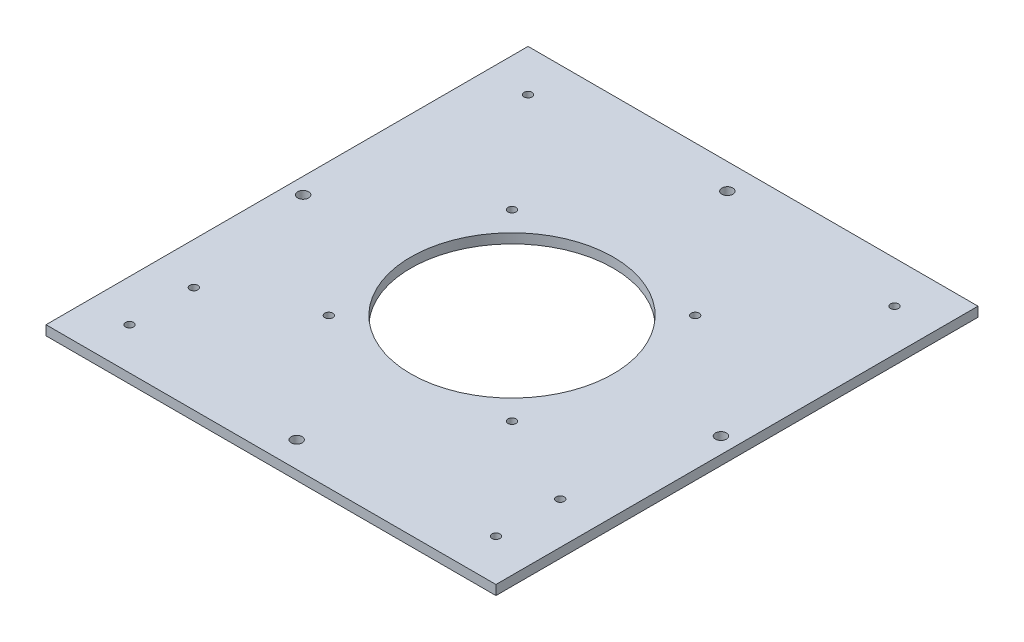
from build123d import *

# Parameters (mm, degrees)
SKETCH_1_W           = 140
SKETCH_1_H           = 3
EXTRUDE_1_DEPTH      = 150
CUT_EXTRUDE_1_REACH  = 5
SKETCH_2_R           = 31.5
HOLE_WIZARD_M3_1_D   = 2.5
HOLE_WIZARD_M3_1_2_D = 3.4
HOLE_WIZARD_M3_2_D   = 2.5


with BuildPart() as part:
    # 草图1 → 拉伸-薄壁1 (new body)
    with BuildSketch(Plane.XY):
        with Locations((82, 225.557982809)):
            Rectangle(SKETCH_1_W, SKETCH_1_H)
    extrude(amount=EXTRUDE_1_DEPTH)

    # 草图2 → 切除-拉伸1 (cut, up to next)
    with BuildSketch(Plane.XZ.offset(-224.057982809), mode=Mode.PRIVATE) as cut_extrude_1_sk1:
        with Locations((82, 75)):
            Circle(SKETCH_2_R)
    cut_extrude_1_tool1 = extrude(cut_extrude_1_sk1.sketch, amount=-CUT_EXTRUDE_1_REACH, mode=Mode.PRIVATE) & part.part
    add(cut_extrude_1_tool1.solids().sort_by_distance((82, 224.057983, 75))[0], mode=Mode.SUBTRACT)

    # Hole Wizard M3 _1 (through all)
    with Locations(Plane(origin=(0, 224.057982809, 0), x_dir=(-1, 0, 0), z_dir=(0, -1, 0))):
        with Locations((-53.5, -103.5), (-53.5, -46.5), (-110.5, -46.5), (-110.5, -103.5)):
            Hole(HOLE_WIZARD_M3_1_D / 2)

    # Hole Wizard M3 _1 2 (through all)
    with Locations(Plane(origin=(0, 224.057982809, 0), x_dir=(-1, 0, 0), z_dir=(0, -1, 0))):
        with Locations((-82, -142), (-147, -75), (-82, -8), (-17, -75)):
            Hole(HOLE_WIZARD_M3_1_2_D / 2)

    # M3 螺纹孔的螺纹孔钻头2 (through all)
    with Locations(Plane(origin=(0, 224.057982809, 0), x_dir=(-1, 0, 0), z_dir=(0, -1, 0))):
        with Locations((-139, -137), (-139, -117), (-139, -13), (-25, -137), (-25, -117), (-25, -13)):
            Hole(HOLE_WIZARD_M3_2_D / 2)


solid = part.part
